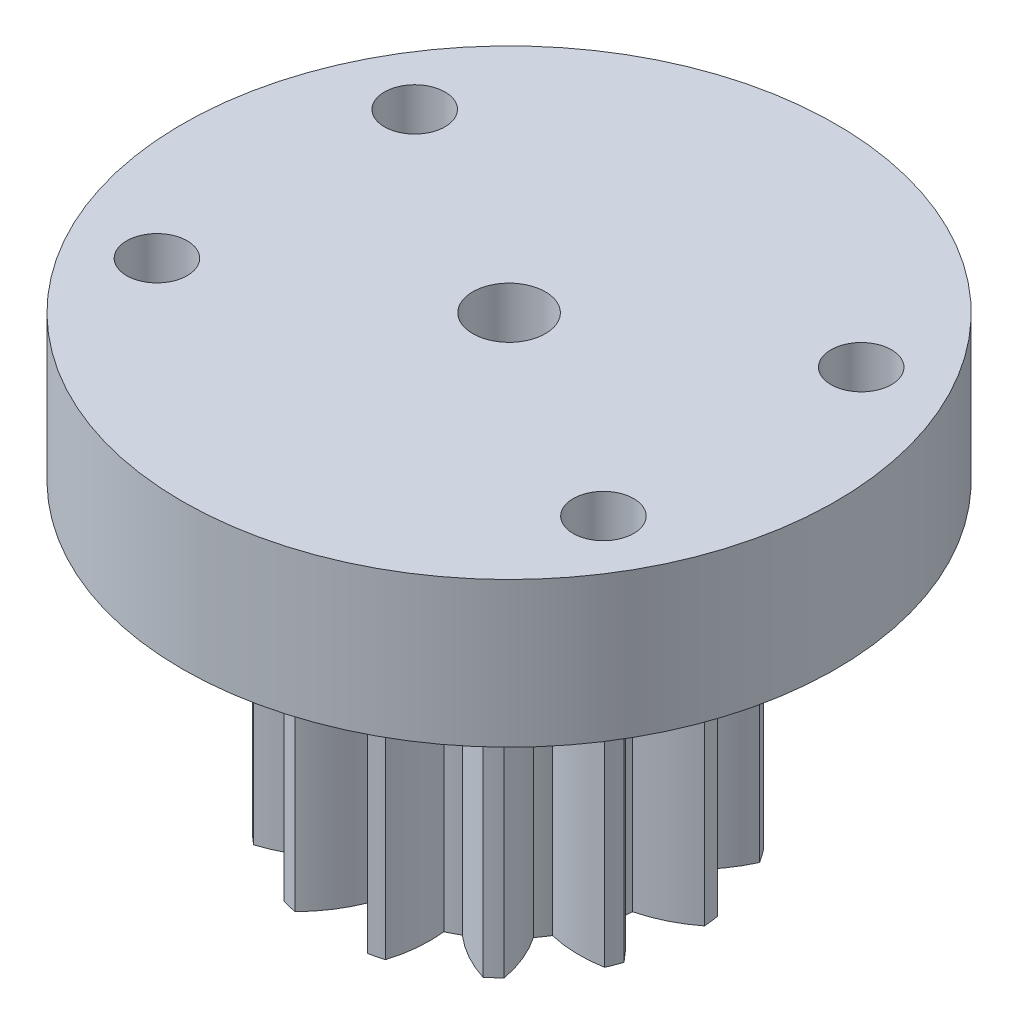
from build123d import *

# Parameters (mm, degrees)
BOSS_EXTRUDE1_DEPTH      = 12.5
SKETCH2_R                = 1.5
CUT_EXTRUDE1_DEPTH       = 13.5
ESBO_O1_R                = 13.5
ESBO_O1_R_2              = 1.5
ESBO_O1_R_3              = 1.25
RESSALTO_EXTRUS_O1_DEPTH = 6


with BuildPart() as part:
    # Sketch1 → Boss-Extrude1 (new body)
    with BuildSketch(Plane(origin=(0, 0, 0), x_dir=(1, 0, 0), z_dir=(0, 1, 0))):
        with BuildLine():
            ThreePointArc((1.04, 5.400777722), (0.783531714, 6.485041414), (0.31, 7.493590595))
            ThreePointArc((0.31, 7.493590595), (0, 7.5), (-0.31, 7.493590595))
            ThreePointArc((-0.31, 7.493590595), (-0.783531714, 6.485041414), (-1.04, 5.400777722))
            ThreePointArc((-1.04, 5.400777722), (-1.316236154, 5.340179996), (-1.588992288, 5.265463276))
            ThreePointArc((-1.588992288, 5.265463276), (-2.319966139, 6.10634434), (-3.207953823, 6.779309129))
            ThreePointArc((-3.207953823, 6.779309129), (-3.48542379, 6.640920192), (-3.756936559, 6.491180762))
            ThreePointArc((-3.756936559, 6.491180762), (-3.707531894, 5.378093653), (-3.430740821, 4.298839078))
            ThreePointArc((-3.430740821, 4.298839078), (-3.64717462, 4.116809115), (-3.853965592, 3.923894649))
            ThreePointArc((-3.853965592, 3.923894649), (-4.891987708, 4.328757368), (-5.991004086, 4.511969642))
            ThreePointArc((-5.991004086, 4.511969642), (-6.172378994, 4.2604856), (-6.343204228, 4.001719645))
            ThreePointArc((-6.343204228, 4.001719645), (-5.782181198, 3.039089449), (-5.035540265, 2.212088208))
            ThreePointArc((-5.035540265, 2.212088208), (-5.142589335, 1.950326879), (-5.236041824, 1.683409046))
            ThreePointArc((-5.236041824, 1.683409046), (-6.343313848, 1.559504249), (-7.401587511, 1.210992284))
            ThreePointArc((-7.401587511, 1.210992284), (-7.445316556, 0.904025102), (-7.476320253, 0.595512782))
            ThreePointArc((-7.476320253, 0.595512782), (-6.532202472, 0.003866477), (-5.486758119, -0.381425412))
            ThreePointArc((-5.486758119, -0.381425412), (-5.459898808, -0.662951741), (-5.418603976, -0.942725282))
            ThreePointArc((-5.418603976, -0.942725282), (-6.341463231, -1.567012498), (-7.116556437, -2.367408811))
            ThreePointArc((-7.116556437, -2.367408811), (-7.01262182, -2.659536653), (-6.896701407, -2.947118882))
            ThreePointArc((-6.896701407, -2.947118882), (-5.785774881, -3.032242258), (-4.68102581, -2.887559066))
            ThreePointArc((-4.68102581, -2.887559066), (-4.526411262, -3.124356107), (-4.359829258, -3.352892609))
            ThreePointArc((-4.359829258, -3.352892609), (-4.886859811, -4.334545567), (-5.201208047, -5.403465078))
            ThreePointArc((-5.201208047, -5.403465078), (-4.973419937, -5.613830611), (-4.737131383, -5.814601127))
            ThreePointArc((-4.737131383, -5.814601127), (-3.713895991, -5.373700834), (-2.802926901, -4.732187738))
            ThreePointArc((-2.802926901, -4.732187738), (-2.555977446, -4.870008141), (-2.302270198, -4.994952646))
            ThreePointArc((-2.302270198, -4.994952646), (-2.312735701, -6.109086484), (-2.094325574, -7.201652615))
            ThreePointArc((-2.094325574, -7.201652615), (-1.794867482, -7.282063631), (-1.492341648, -7.350028327))
            ThreePointArc((-1.492341648, -7.350028327), (-0.791208287, -6.484109309), (-0.282711218, -5.492729228))
            ThreePointArc((-0.282711218, -5.492729228), (0, -5.5), (0.282711218, -5.492729228))
            ThreePointArc((0.282711218, -5.492729228), (0.791208287, -6.484109309), (1.492341648, -7.350028327))
            ThreePointArc((1.492341648, -7.350028327), (1.794867482, -7.282063631), (2.094325574, -7.201652615))
            ThreePointArc((2.094325574, -7.201652615), (2.312735701, -6.109086484), (2.302270198, -4.994952646))
            ThreePointArc((2.302270198, -4.994952646), (2.555977446, -4.870008141), (2.802926901, -4.732187738))
            ThreePointArc((2.802926901, -4.732187738), (3.713895991, -5.373700834), (4.737131383, -5.814601127))
            ThreePointArc((4.737131383, -5.814601127), (4.973419937, -5.613830611), (5.201208047, -5.403465078))
            ThreePointArc((5.201208047, -5.403465078), (4.886859811, -4.334545567), (4.359829258, -3.352892609))
            ThreePointArc((4.359829258, -3.352892609), (4.526411262, -3.124356107), (4.68102581, -2.887559066))
            ThreePointArc((4.68102581, -2.887559066), (5.785774881, -3.032242258), (6.896701407, -2.947118882))
            ThreePointArc((6.896701407, -2.947118882), (7.01262182, -2.659536653), (7.116556437, -2.367408811))
            ThreePointArc((7.116556437, -2.367408811), (6.341463231, -1.567012498), (5.418603976, -0.942725282))
            ThreePointArc((5.418603976, -0.942725282), (5.459898808, -0.662951741), (5.486758119, -0.381425412))
            ThreePointArc((5.486758119, -0.381425412), (6.532202472, 0.003866477), (7.476320253, 0.595512782))
            ThreePointArc((7.476320253, 0.595512782), (7.445316556, 0.904025102), (7.401587511, 1.210992284))
            ThreePointArc((7.401587511, 1.210992284), (6.343313848, 1.559504249), (5.236041824, 1.683409046))
            ThreePointArc((5.236041824, 1.683409046), (5.142589335, 1.950326879), (5.035540265, 2.212088208))
            ThreePointArc((5.035540265, 2.212088208), (5.782181198, 3.039089449), (6.343204228, 4.001719645))
            ThreePointArc((6.343204228, 4.001719645), (6.172378994, 4.2604856), (5.991004086, 4.511969642))
            ThreePointArc((5.991004086, 4.511969642), (4.891987708, 4.328757368), (3.853965592, 3.923894649))
            ThreePointArc((3.853965592, 3.923894649), (3.64717462, 4.116809115), (3.430740821, 4.298839078))
            ThreePointArc((3.430740821, 4.298839078), (3.707531894, 5.378093653), (3.756936559, 6.491180762))
            ThreePointArc((3.756936559, 6.491180762), (3.48542379, 6.640920192), (3.207953823, 6.779309129))
            ThreePointArc((3.207953823, 6.779309129), (2.319966139, 6.10634434), (1.588992288, 5.265463276))
            ThreePointArc((1.588992288, 5.265463276), (1.316236154, 5.340179996), (1.04, 5.400777722))
        make_face()
    extrude(amount=BOSS_EXTRUDE1_DEPTH)

    # Sketch2 → Cut-Extrude1 (cut, through all)
    with BuildSketch(Plane(origin=(0, 12.5, 0), x_dir=(1, 0, 0), z_dir=(0, 1, 0))):
        Circle(SKETCH2_R)
    extrude(amount=-CUT_EXTRUDE1_DEPTH, mode=Mode.SUBTRACT)

    # Esboço1 → Ressalto-extrusão1 (add)
    with BuildSketch(Plane(origin=(0, 12.5, 0), x_dir=(1, 0, 0), z_dir=(0, 1, 0))):
        Circle(ESBO_O1_R)
        Circle(ESBO_O1_R_2, mode=Mode.SUBTRACT)
        with Locations((9.22317055, 5.325)):
            Circle(ESBO_O1_R_3, mode=Mode.SUBTRACT)
        with Locations((9.22317055, -5.325)):
            Circle(ESBO_O1_R_3, mode=Mode.SUBTRACT)
        with Locations((-9.22317055, -5.325)):
            Circle(ESBO_O1_R_3, mode=Mode.SUBTRACT)
        with Locations((-9.22317055, 5.325)):
            Circle(ESBO_O1_R_3, mode=Mode.SUBTRACT)
    extrude(amount=RESSALTO_EXTRUS_O1_DEPTH)


solid = part.part
